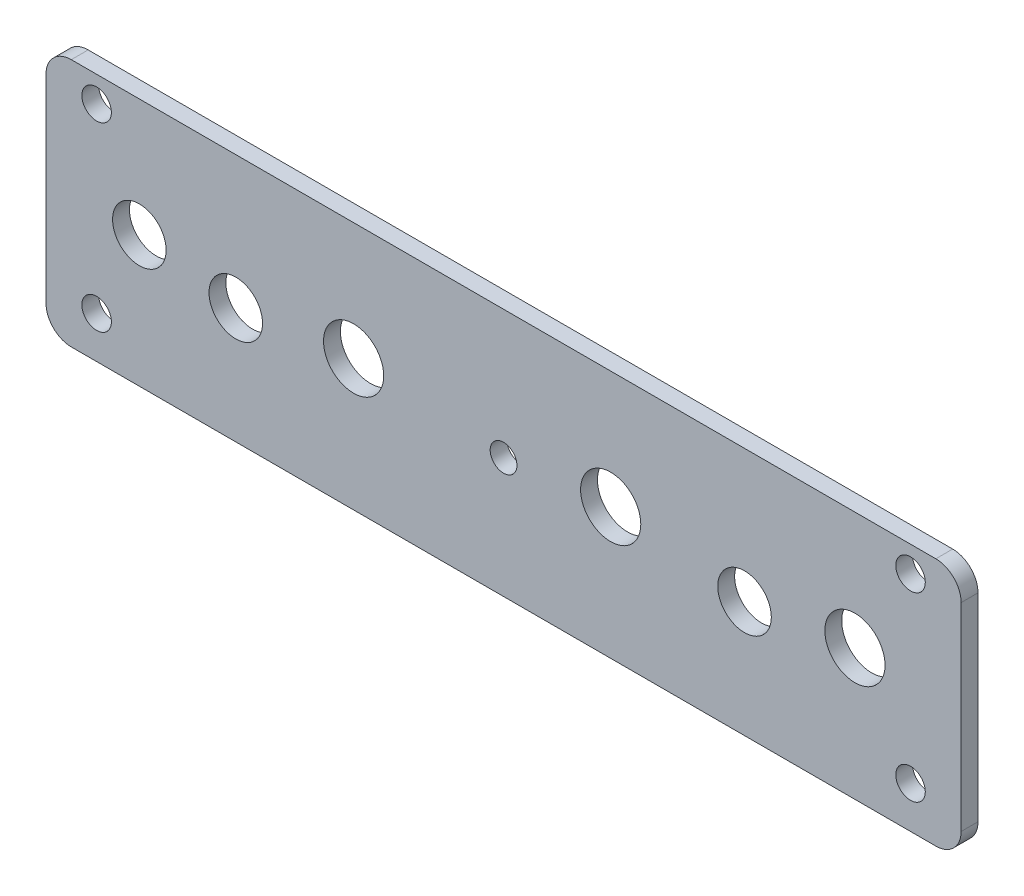
from build123d import *

# Parameters (mm, degrees)
SKETCH1_R           = 1.5875
SKETCH1_R_2         = 3.5687
SKETCH1_R_3         = 3.175
SKETCH1_R_4         = 1.75
BOSS_EXTRUDE1_DEPTH = 2


with BuildPart() as part:
    # Sketch1 → Boss-Extrude1 (new body)
    with BuildSketch(Plane.XY):
        with BuildLine():
            Line((51.25, -14.75), (-51.25, -14.75))
            ThreePointArc((-51.25, -14.75), (-53.371320344, -13.871320344), (-54.25, -11.75))
            Line((-54.25, -11.75), (-54.25, 11.75))
            ThreePointArc((-54.25, 11.75), (-53.371320344, 13.871320344), (-51.25, 14.75))
            Line((-51.25, 14.75), (51.25, 14.75))
            ThreePointArc((51.25, 14.75), (53.371320344, 13.871320344), (54.25, 11.75))
            Line((54.25, 11.75), (54.25, -11.75))
            ThreePointArc((54.25, -11.75), (53.371320344, -13.871320344), (51.25, -14.75))
        make_face()
        with Locations((0, -0.5)):
            Circle(SKETCH1_R, mode=Mode.SUBTRACT)
        with Locations((-17.78, 0.8)):
            Circle(SKETCH1_R_2, mode=Mode.SUBTRACT)
        with Locations((-31.75, -1)):
            Circle(SKETCH1_R_3, mode=Mode.SUBTRACT)
        with Locations((-43.18, 0.8)):
            Circle(SKETCH1_R_3, mode=Mode.SUBTRACT)
        with Locations((12.7, 0.8)):
            Circle(SKETCH1_R_2, mode=Mode.SUBTRACT)
        with Locations((28.57, -1)):
            Circle(SKETCH1_R_3, mode=Mode.SUBTRACT)
        with Locations((41.66, 0.8)):
            Circle(SKETCH1_R_2, mode=Mode.SUBTRACT)
        with Locations((48.25, 11.7)):
            Circle(SKETCH1_R_4, mode=Mode.SUBTRACT)
        with Locations((48.25, -9.8)):
            Circle(SKETCH1_R_4, mode=Mode.SUBTRACT)
        with Locations((-48.25, 11.7)):
            Circle(SKETCH1_R_4, mode=Mode.SUBTRACT)
        with Locations((-48.25, -9.8)):
            Circle(SKETCH1_R_4, mode=Mode.SUBTRACT)
    extrude(amount=BOSS_EXTRUDE1_DEPTH)


solid = part.part
